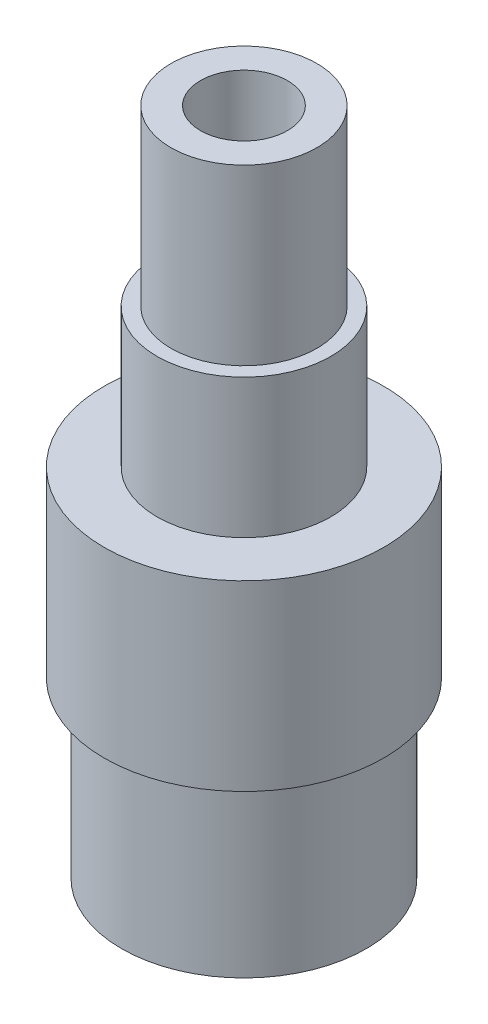
from build123d import *


with BuildPart() as part:
    # Sketch1 → Revolve1 (revolve)
    with BuildSketch(Plane.XY):
        Polygon((-3.175, 0), (-5.334, 0), (-5.334, -12.7), (-6.35, -12.7), (-6.35, -22.86), (-10.2108, -22.86), (-10.2108, -36.195), (-8.9408, -36.195), (-8.9408, -48.895), (-4.445, -48.895), (-4.445, -43.18), (-3.175, -43.18), align=None)
    revolve(axis=Axis((0, 0, 0), (0, -1, 0)))


solid = part.part
